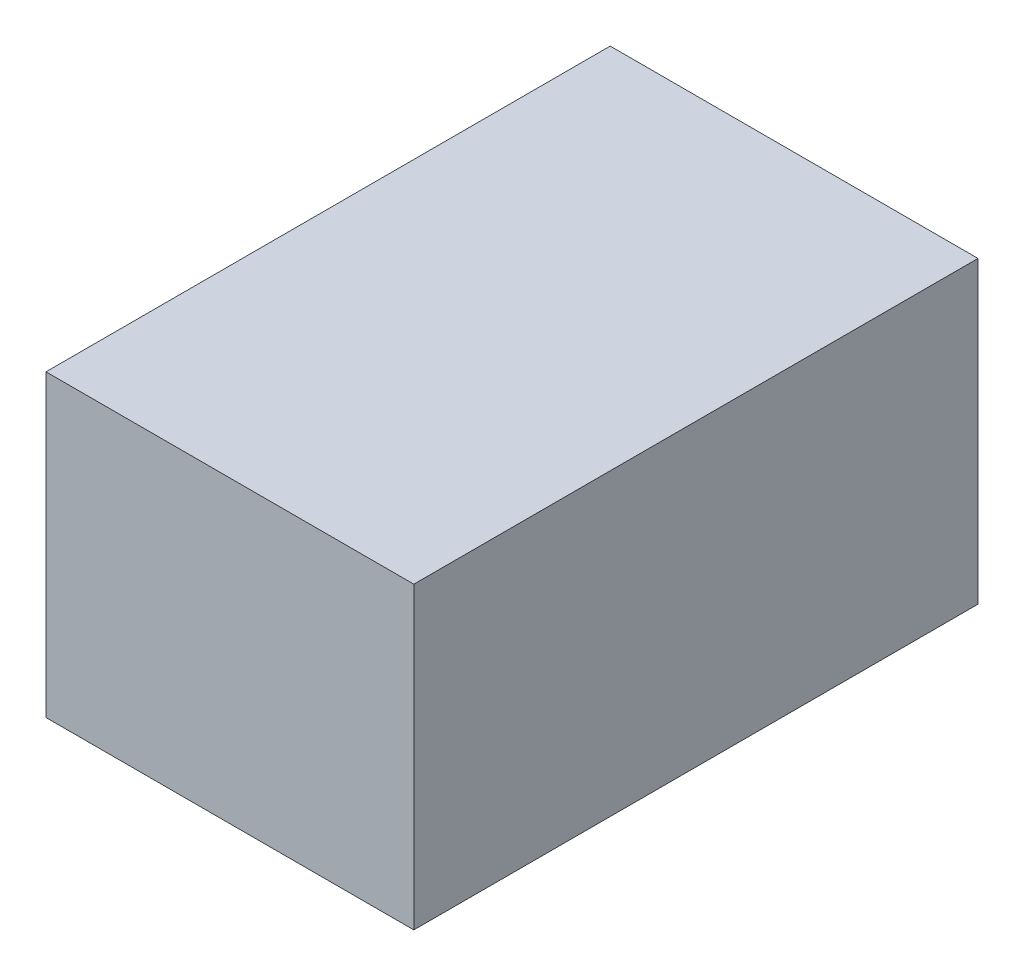
from build123d import *

# Parameters (mm, degrees)
SKETCH1_W           = 218.4
SKETCH1_H           = 177.8
BOSS_EXTRUDE1_DEPTH = 335


with BuildPart() as part:
    # Sketch1 → Boss-Extrude1 (new body)
    with BuildSketch(Plane.XY):
        Rectangle(SKETCH1_W, SKETCH1_H)
    extrude(amount=BOSS_EXTRUDE1_DEPTH)


solid = part.part
